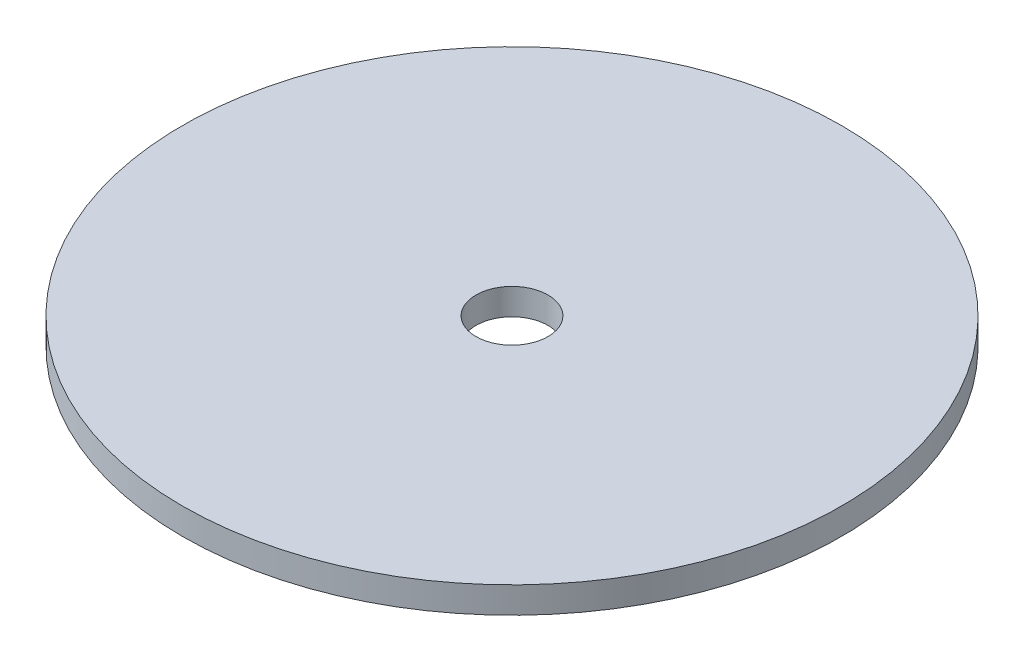
from build123d import *

# Parameters (mm, degrees)
SKETCH1_R           = 37.5
SKETCH1_R_2         = 4.1
BOSS_EXTRUDE1_DEPTH = 3


with BuildPart() as part:
    # Sketch1 → Boss-Extrude1 (new body)
    with BuildSketch(Plane(origin=(0, 0, 0), x_dir=(1, 0, 0), z_dir=(0, 1, 0))):
        Circle(SKETCH1_R)
        Circle(SKETCH1_R_2, mode=Mode.SUBTRACT)
    extrude(amount=BOSS_EXTRUDE1_DEPTH)


solid = part.part
